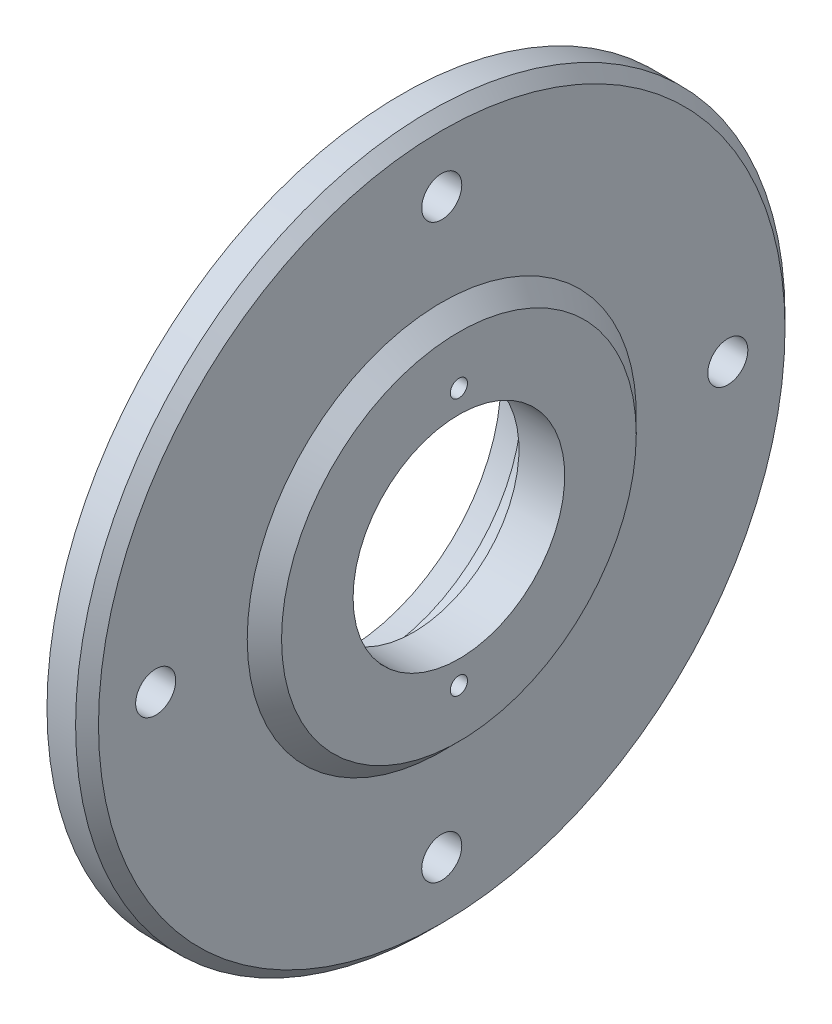
from build123d import *

# Parameters (mm, degrees)
ZKOSEN_1_SIZE            = 2
SKICA2_R                 = 1.5
ODEBRAT_VYSUNUT_M1_DEPTH = 8
KRUHOV_POLE1_COUNT       = 2
SKICA3_R                 = 3.5
ODEBRAT_VYSUNUT_M2_DEPTH = 7
KRUHOV_POLE2_COUNT       = 4


with BuildPart() as part:
    # Skica1 → Rotovat1 (revolve)
    with BuildSketch(Plane.XY):
        Polygon((-2, 62), (-2, 34), (-12, 34), (-12, 27.339745962), (-7, 26), (0, 26), (0, 18.5), (8, 18.5), (8, 31), (5, 34), (5, 62), align=None)
    revolve(axis=Axis((-20.777479893, 0, 0), (1, 0, 0)))

    # Zkosení1
    zkosen_1_edges = [part.edges().sort_by_distance(p)[0] for p in [
        (5, -62, 0),
    ]]
    chamfer(zkosen_1_edges, length=ZKOSEN_1_SIZE)

    # Skica2 → Odebrat vysunutím1 (cut)
    with BuildSketch(Plane(origin=(8, 0, 0), x_dir=(0, 0, -1), z_dir=(1, 0, 0))):
        with Locations((0, 22.5)):
            Circle(SKICA2_R)
    odebrat_vysunut_m1 = extrude(amount=-ODEBRAT_VYSUNUT_M1_DEPTH, mode=Mode.SUBTRACT)

    # Kruhové pole1: Odebrat vysunutím1 ×2 about axis
    kruhov_pole1_axis = Axis((0, 0, 0), (1, 0, 0))
    for i in range(1, KRUHOV_POLE1_COUNT):
        add(odebrat_vysunut_m1.rotate(kruhov_pole1_axis, i * 360 / KRUHOV_POLE1_COUNT), mode=Mode.SUBTRACT)

    # Skica3 → Odebrat vysunutím2 (cut)
    with BuildSketch(Plane(origin=(5, 0, 0), x_dir=(0, 0, -1), z_dir=(1, 0, 0))):
        with Locations((0, 50)):
            Circle(SKICA3_R)
    odebrat_vysunut_m2 = extrude(amount=-ODEBRAT_VYSUNUT_M2_DEPTH, mode=Mode.SUBTRACT)

    # Kruhové pole2: Odebrat vysunutím2 ×4 about axis
    kruhov_pole2_axis = Axis((0, 0, 0), (1, 0, 0))
    for i in range(1, KRUHOV_POLE2_COUNT):
        add(odebrat_vysunut_m2.rotate(kruhov_pole2_axis, i * 360 / KRUHOV_POLE2_COUNT), mode=Mode.SUBTRACT)


solid = part.part
